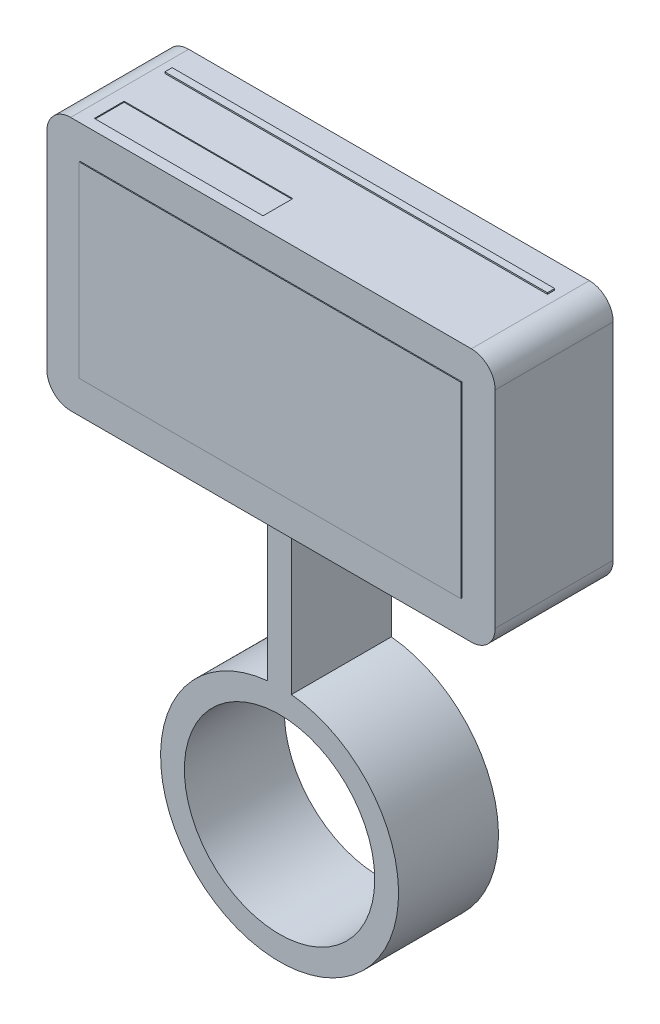
from build123d import *

# Parameters (mm, degrees)
SKETCH1_R                = 20
BOSS_EXTRUDE1_DEPTH      = 21
SKETCH2_W                = 94.201321488
SKETCH2_H                = 53.383054243
BOSS_EXTRUDE2_DEPTH      = 2
BOSS_EXTRUDE2_DEPTH_BACK = 23
SKETCH3_R                = 21.466238287
SKETCH3_R_2              = 16.583389224
BOSS_EXTRUDE3_DEPTH      = 3
SKETCH5_R                = 1.673213121
SKETCH5_R_2              = 1.750359772
SKETCH5_W                = 10.5723409
SKETCH5_H                = 9.65300691
BOSS_EXTRUDE4_DEPTH      = 1
SKETCH6_R                = 1.145286075
CUT_EXTRUDE1_DEPTH       = 0.5
FILLET1_R                = 5
SKETCH7_W                = 80.380422704
SKETCH7_H                = 1.528144919
BOSS_EXTRUDE5_DEPTH      = 0.3
SKETCH8_W                = 35.452962105
SKETCH8_H                = 6.265394165
CUT_EXTRUDE2_DEPTH       = 0.2
SKETCH9_W                = 80.201321488
SKETCH9_H                = 39.383054243
CUT_EXTRUDE3_DEPTH       = 0.2


with BuildPart() as part:
    # Sketch1 → Boss-Extrude1 (new body)
    with BuildSketch(Plane.XY):
        with BuildLine():
            Line((-2.5, 4.874685928), (-2.5, 35.297974782))
            Line((-2.5, 35.297974782), (2.5, 35.297974782))
            Line((2.5, 35.297974782), (2.5, 4.874685928))
            ThreePointArc((2.5, 4.874685928), (0, -45), (-2.5, 4.874685928))
        make_face()
        with Locations((0, -20)):
            Circle(SKETCH1_R, mode=Mode.SUBTRACT)
    extrude(amount=BOSS_EXTRUDE1_DEPTH)

    # Sketch2 → Boss-Extrude2 (add, two sides)
    with BuildSketch(Plane(origin=(0, 0, 0), x_dir=(-1, 0, 0), z_dir=(0, 0, -1))) as boss_extrude2_sk:
        with Locations((0, 61.80682757)):
            Rectangle(SKETCH2_W, SKETCH2_H)
    extrude(amount=BOSS_EXTRUDE2_DEPTH)
    extrude(boss_extrude2_sk.sketch, amount=-BOSS_EXTRUDE2_DEPTH_BACK)

    # Sketch3 → Boss-Extrude3 (add)
    with BuildSketch(Plane(origin=(0, 0, -2), x_dir=(-1, 0, 0), z_dir=(0, 0, -1))):
        with Locations((0, 62.480667846)):
            Circle(SKETCH3_R)
        with Locations((0, 62.480667846)):
            Circle(SKETCH3_R_2, mode=Mode.SUBTRACT)
    extrude(amount=BOSS_EXTRUDE3_DEPTH)

    # Sketch5 → Boss-Extrude4 (add)
    with BuildSketch(Plane(origin=(0, 0, -2), x_dir=(-1, 0, 0), z_dir=(0, 0, -1))):
        with Locations((31.252984021, 84.498349336)):
            Circle(SKETCH5_R)
        with Locations((40.446323934, 84.498349336)):
            Circle(SKETCH5_R_2)
        with Locations((-36.370926049, 78.042958424)):
            Rectangle(SKETCH5_W, SKETCH5_H)
    extrude(amount=BOSS_EXTRUDE4_DEPTH)

    # Sketch6 → Cut-Extrude1 (cut)
    with BuildSketch(Plane(origin=(0, 0, -3), x_dir=(-1, 0, 0), z_dir=(0, 0, -1))):
        with Locations((31.252984021, 84.498349336)):
            Circle(SKETCH6_R)
    extrude(amount=-CUT_EXTRUDE1_DEPTH, mode=Mode.SUBTRACT)

    # Fillet1
    fillet1_edges = [part.edges().sort_by_distance(p)[0] for p in [
        (47.100660744, 35.115300448, 10.5),
        (-47.100660744, 35.115300448, 10.5),
        (-47.100660744, 88.498354691, 10.5),
        (47.100660744, 88.498354691, 10.5),
    ]]
    fillet(fillet1_edges, radius=FILLET1_R)

    # Sketch7 → Boss-Extrude5 (add)
    with BuildSketch(Plane(origin=(0, 88.498354691, 0), x_dir=(1, 0, 0), z_dir=(0, 1, 0))):
        with Locations((0, -4.147120871)):
            Rectangle(SKETCH7_W, SKETCH7_H)
    extrude(amount=BOSS_EXTRUDE5_DEPTH)

    # Sketch8 → Cut-Extrude2 (cut)
    with BuildSketch(Plane(origin=(0, 88.498354691, 0), x_dir=(1, 0, 0), z_dir=(0, 1, 0))):
        with Locations((-21.699657841, -17.365574415)):
            Rectangle(SKETCH8_W, SKETCH8_H)
    extrude(amount=-CUT_EXTRUDE2_DEPTH, mode=Mode.SUBTRACT)

    # Sketch9 → Cut-Extrude3 (cut)
    with BuildSketch(Plane.XY.offset(23)):
        with BuildLine():
            Line((-47.100660744, 83.498354691), (-47.100660744, 40.115300448))
            ThreePointArc((-47.100660744, 40.115300448), (-45.63619465, 36.579766542), (-42.100660744, 35.115300448))
            Line((-42.100660744, 35.115300448), (42.100660744, 35.115300448))
            ThreePointArc((42.100660744, 35.115300448), (45.63619465, 36.579766542), (47.100660744, 40.115300448))
            Line((47.100660744, 40.115300448), (47.100660744, 83.498354691))
            ThreePointArc((47.100660744, 83.498354691), (45.63619465, 87.033888597), (42.100660744, 88.498354691))
            Line((42.100660744, 88.498354691), (-42.100660744, 88.498354691))
            ThreePointArc((-42.100660744, 88.498354691), (-45.63619465, 87.033888597), (-47.100660744, 83.498354691))
        make_face()
        with Locations((0, 61.80682757)):
            Rectangle(SKETCH9_W, SKETCH9_H, mode=Mode.SUBTRACT)
    extrude(amount=-CUT_EXTRUDE3_DEPTH, mode=Mode.SUBTRACT)


with BuildPart() as body_2:
    # Sketch4 → Revolve2 (revolve)
    with BuildSketch(Plane(origin=(0, 0, 0), x_dir=(0, 0, -1), z_dir=(1, 0, 0))):
        with BuildLine():
            Line((5, 79.06405707), (5, 62.480667846))
            Line((5, 62.480667846), (9.357251045, 62.480667846))
            ThreePointArc((9.357251045, 62.480667846), (8.01892353, 70.993149013), (5, 79.06405707))
        make_face()
    revolve(axis=Axis((0, 62.480667846, -5), (0, 0, -1)))


solid = Compound([part.part, body_2.part])
